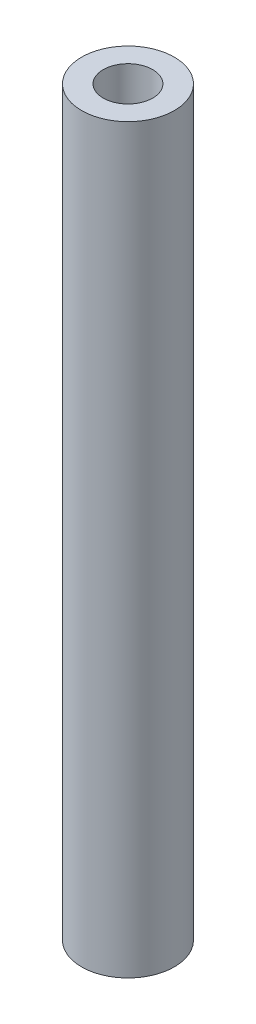
from build123d import *

# Parameters (mm, degrees)
SKETCH1_R           = 7.5
BOSS_EXTRUDE1_DEPTH = 120
SKETCH2_R           = 5
CUT_EXTRUDE1_DEPTH  = 15
SKETCH3_R           = 3
CUT_EXTRUDE4_DEPTH  = 10
SKETCH4_R           = 4
CUT_EXTRUDE5_DEPTH  = 12


with BuildPart() as part:
    # Sketch1 → Boss-Extrude1 (new body)
    with BuildSketch(Plane(origin=(0, 0, 0), x_dir=(1, 0, 0), z_dir=(0, 1, 0))):
        Circle(SKETCH1_R)
    extrude(amount=BOSS_EXTRUDE1_DEPTH)

    # Sketch2 → Cut-Extrude1 (cut)
    with BuildSketch(Plane.XZ):
        Circle(SKETCH2_R)
    extrude(amount=-CUT_EXTRUDE1_DEPTH, mode=Mode.SUBTRACT)

    # Sketch3 → Cut-Extrude4 (cut)
    with BuildSketch(Plane.XY):
        with Locations((0, 10)):
            Circle(SKETCH3_R)
    extrude(amount=-CUT_EXTRUDE4_DEPTH, mode=Mode.SUBTRACT)

    # Sketch4 → Cut-Extrude5 (cut)
    with BuildSketch(Plane(origin=(0, 120, 0), x_dir=(1, 0, 0), z_dir=(0, 1, 0))):
        Circle(SKETCH4_R)
    extrude(amount=-CUT_EXTRUDE5_DEPTH, mode=Mode.SUBTRACT)


solid = part.part
